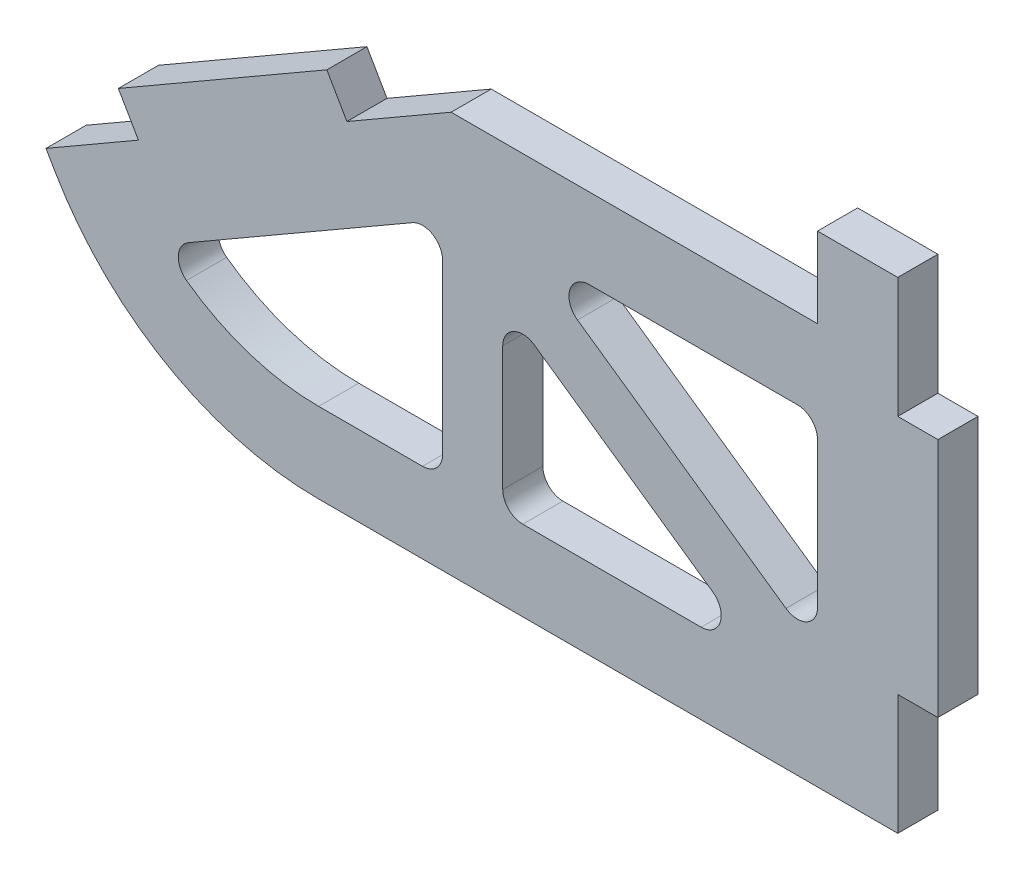
from build123d import *

# Parameters (mm, degrees)
SKETCH1_W           = 152.4
SKETCH1_H           = 76.2
BOSS_EXTRUDE1_DEPTH = 6.35
SKETCH2_W           = 6.35
SKETCH2_H           = 38.1
BOSS_EXTRUDE2_DEPTH = 6.35
CUT_EXTRUDE1_DEPTH  = 7.35
CUT_EXTRUDE2_DEPTH  = 7.35
BOSS_EXTRUDE3_DEPTH = 6.35
CUT_EXTRUDE3_DEPTH  = 7.35
FILLET1_R           = 48.26
CUT_EXTRUDE4_DEPTH  = 7.35
EXTRUDE_THIN2_DEPTH = 6.35
FILLET2_R           = 3.175


with BuildPart() as part:
    # Sketch1 → Boss-Extrude1 (new body)
    with BuildSketch(Plane.XY):
        with Locations((-76.2, -38.1)):
            Rectangle(SKETCH1_W, SKETCH1_H)
    extrude(amount=BOSS_EXTRUDE1_DEPTH)

    # Sketch2 → Boss-Extrude2 (add)
    with BuildSketch(Plane.XY.offset(6.35)):
        with Locations((3.175, -38.1)):
            Rectangle(SKETCH2_W, SKETCH2_H)
    extrude(amount=-BOSS_EXTRUDE2_DEPTH)

    # Sketch3 → Cut-Extrude1 (cut, through all)
    with BuildSketch(Plane.XY.offset(6.35)):
        Polygon((-152.4, -59.878913996), (-70.683723912, -12.7), (-12.7, -12.7), (-12.7, 0), (-152.4, 0), align=None)
    extrude(amount=-CUT_EXTRUDE1_DEPTH, mode=Mode.SUBTRACT)

    # Sketch4 → Cut-Extrude2 (cut, through all)
    with BuildSketch(Plane.XY.offset(6.35)):
        Polygon((-152.4, -59.878913996), (-133.35, -76.2), (-152.4, -76.2), align=None)
    extrude(amount=-CUT_EXTRUDE2_DEPTH, mode=Mode.SUBTRACT)

    # Sketch5 → Boss-Extrude3 (add)
    with BuildSketch(Plane.XY.offset(6.35)):
        Polygon((-87.181507854, -22.225), (-90.356507854, -16.725738686), (-123.352075739, -35.775738686), (-120.177075739, -41.275), align=None)
    extrude(amount=-BOSS_EXTRUDE3_DEPTH)

    # Sketch6 → Cut-Extrude3 (cut, through all)
    with BuildSketch(Plane.XY.offset(6.35)):
        Polygon((-134.802363795, -49.718913996), (-119.513501663, -76.2), (-133.35, -76.2), (-152.4, -59.878913996), align=None)
    extrude(amount=-CUT_EXTRUDE3_DEPTH, mode=Mode.SUBTRACT)

    # Fillet1
    fillet1_edges = [part.edges().sort_by_distance(p)[0] for p in [
        (-119.513501663, -76.2, 3.175),
    ]]
    fillet(fillet1_edges, radius=FILLET1_R)

    # Sketch7 → Cut-Extrude4 (cut, through all)
    with BuildSketch(Plane.XY.offset(6.35)):
        with BuildLine():
            Line((-102.82855311, -45.923522628), (-91.830030482, -39.573522628))
            Line((-91.830030482, -39.573522628), (-67.280769168, -25.4))
            Line((-67.280769168, -25.4), (-12.7, -25.4))
            Line((-12.7, -25.4), (-12.7, -31.75))
            Line((-12.7, -31.75), (-12.7, -44.45))
            Line((-12.7, -44.45), (-12.7, -63.5))
            Line((-12.7, -63.5), (-91.650577671, -63.5))
            ThreePointArc((-91.650577671, -63.5), (-104.882957084, -60.946328713), (-116.214822021, -53.652088587))
            Line((-116.214822021, -53.652088587), (-102.82855311, -45.923522628))
        make_face()
    extrude(amount=-CUT_EXTRUDE4_DEPTH, mode=Mode.SUBTRACT)

    # Sketch8 → Extrude-Thin2 (add)
    with BuildSketch(Plane.XY.offset(6.35)):
        Polygon((-9.974003812, -59.594830217), (-72.043269168, -16.267499985), (-72.043269168, -63.5), (-62.518269168, -63.5), (-62.518269168, -34.532500015), (-15.425996188, -67.405169783), align=None)
    extrude(amount=-EXTRUDE_THIN2_DEPTH)

    # Fillet2
    fillet2_edges = [part.edges().sort_by_distance(p)[0] for p in [
        (-116.214822021, -53.652088587, 3.175),
        (-12.7, -25.4, 3.175),
        (-21.020410111, -63.5, 3.175),
        (-12.7, -57.691953868, 3.175),
        (-58.960359057, -25.4, 3.175),
        (-72.043269168, -63.5, 3.175),
        (-72.043269168, -28.149630657, 3.175),
        (-62.518269168, -34.532500015, 3.175),
        (-62.518269168, -63.5, 3.175),
    ]]
    fillet(fillet2_edges, radius=FILLET2_R)


solid = part.part
